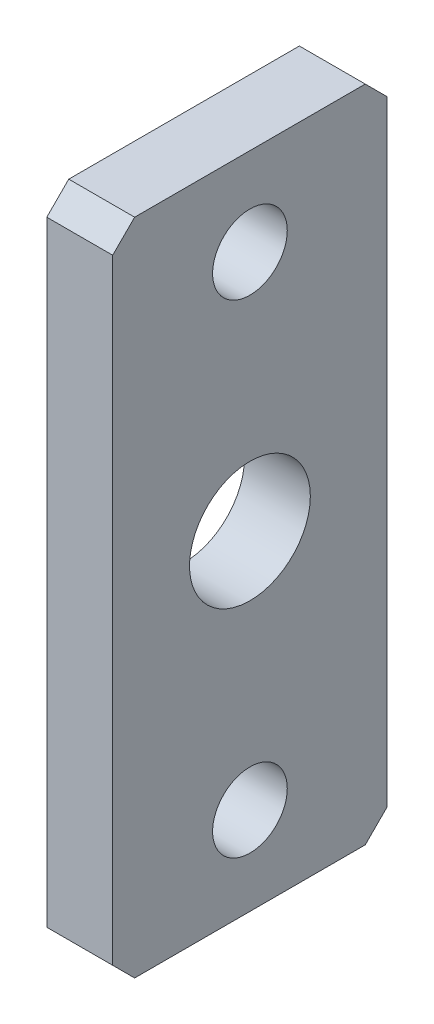
from build123d import *

# Parameters (mm, degrees)
SKETCH1_W                  = 25
SKETCH1_H                  = 60
BOSS_EXTRUDE1_DEPTH        = 6
F_11_0_11_DIAMETER_HOLE1_D = 11
M8X1_25_TAPPED_HOLE1_D     = 6.8
CHAMFER1_SIZE              = 2


with BuildPart() as part:
    # Sketch1 → Boss-Extrude1 (new body)
    with BuildSketch(Plane(origin=(0, 0, 0), x_dir=(0, 0, -1), z_dir=(1, 0, 0))):
        with Locations((12.5, 0)):
            Rectangle(SKETCH1_W, SKETCH1_H)
    extrude(amount=-BOSS_EXTRUDE1_DEPTH)

    # Ø11.0 (11) Diameter Hole1 (through all)
    with Locations(Plane(origin=(0, 0, 0), x_dir=(0, 0, -1), z_dir=(1, 0, 0))):
        with Locations((12.5, 0)):
            Hole(F_11_0_11_DIAMETER_HOLE1_D / 2)

    # M8x1.25 Tapped Hole1 (through all)
    with Locations(Plane(origin=(0, 0, 0), x_dir=(0, 0, -1), z_dir=(1, 0, 0))):
        with Locations((12.5, 22), (12.5, -22)):
            Hole(M8X1_25_TAPPED_HOLE1_D / 2)

    # Chamfer1
    chamfer1_edges = [part.edges().sort_by_distance(p)[0] for p in [
        (-3, 30, 0),
        (-3, 30, -25),
        (-3, -30, -25),
        (-3, -30, 0),
    ]]
    chamfer(chamfer1_edges, length=CHAMFER1_SIZE)


solid = part.part
